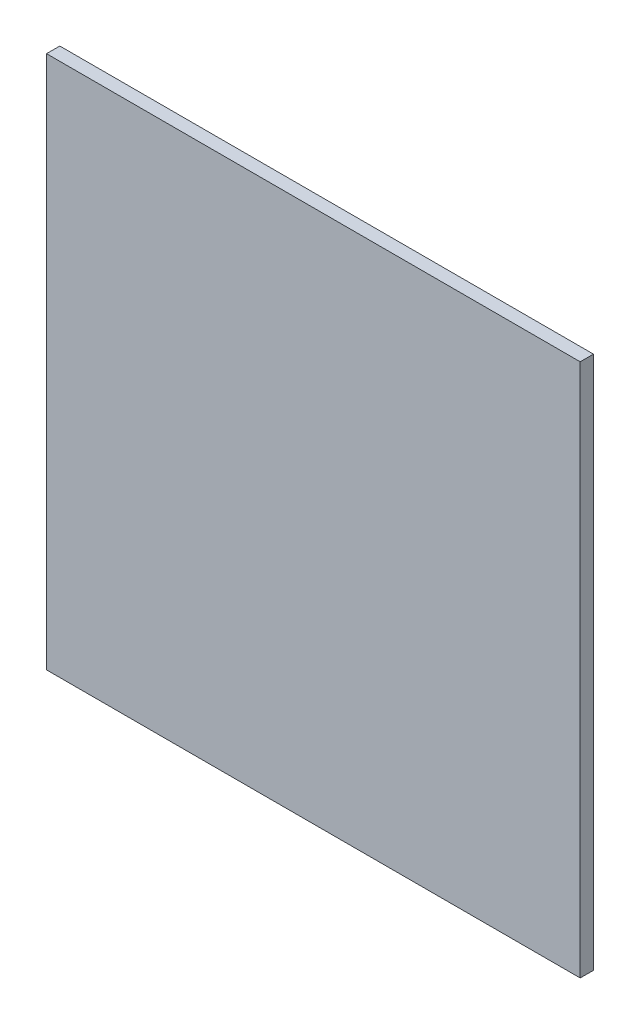
from build123d import *

# Parameters (mm, degrees)
SKETCH1_W           = 127.762
SKETCH1_H           = 127.762
BOSS_EXTRUDE1_DEPTH = 3.175


with BuildPart() as part:
    # Sketch1 → Boss-Extrude1 (new body)
    with BuildSketch(Plane.XY):
        Rectangle(SKETCH1_W, SKETCH1_H)
    extrude(amount=BOSS_EXTRUDE1_DEPTH)


solid = part.part
